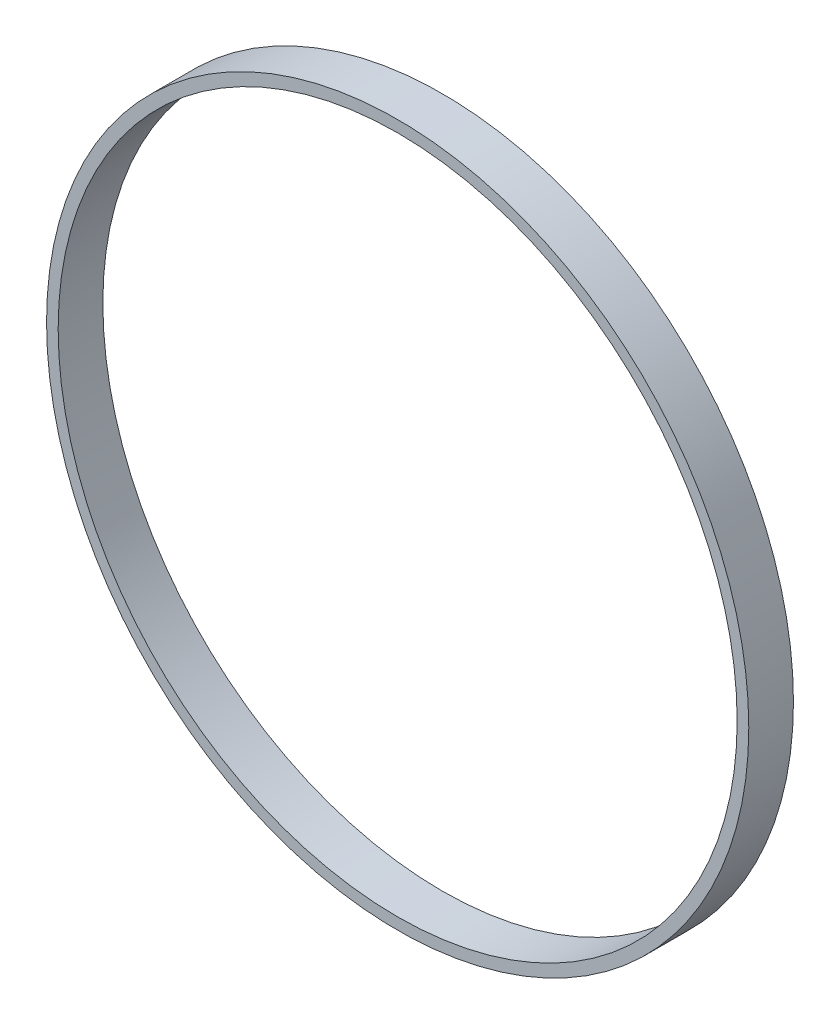
from build123d import *

# Parameters (mm, degrees)
SKETCH1_R           = 78.6
SKETCH1_R_2         = 76
BOSS_EXTRUDE1_DEPTH = 10


with BuildPart() as part:
    # Sketch1 → Boss-Extrude1 (new body)
    with BuildSketch(Plane.XY):
        Circle(SKETCH1_R)
        Circle(SKETCH1_R_2, mode=Mode.SUBTRACT)
    extrude(amount=BOSS_EXTRUDE1_DEPTH)


solid = part.part
